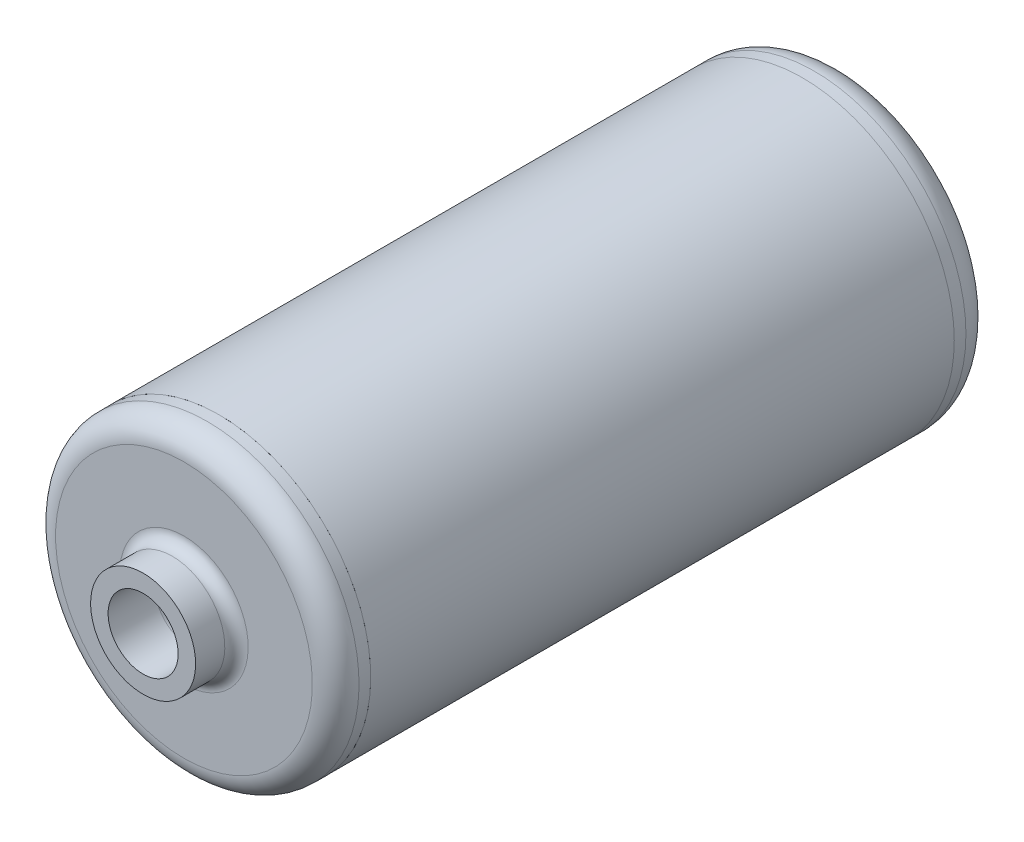
from build123d import *

# Parameters (mm, degrees)
SALIENTE_EXTRUIR1_DEPTH      = 50
SALIENTE_EXTRUIR1_DEPTH_BACK = 50
CROQUIS1_R                   = 26
CROQUIS1_R_2                 = 22


with BuildPart() as part:
    # Croquis1 → Saliente-Extruir1 (new, two sides: drawn at the far end of the back side and taken through both)
    with BuildSketch(Plane.XY.offset(-SALIENTE_EXTRUIR1_DEPTH_BACK)):
        Circle(CROQUIS1_R)
        Circle(CROQUIS1_R_2, mode=Mode.SUBTRACT)
    extrude(amount=SALIENTE_EXTRUIR1_DEPTH + SALIENTE_EXTRUIR1_DEPTH_BACK)


with BuildPart() as body_2:
    # Croquis2 → Revolución2 (revolve)
    with BuildSketch(Plane(origin=(0, 0, 0), x_dir=(0, 0, -1), z_dir=(1, 0, 0))):
        with BuildLine():
            Line((-50, 22), (-43, 22))
            Line((-43, 22), (-43, 21))
            ThreePointArc((-43, 21), (-43.585786438, 19.585786438), (-45, 19))
            Line((-45, 19), (-49, 19))
            ThreePointArc((-49, 19), (-51.828427125, 17.828427125), (-53, 15))
            Line((-53, 15), (-53, 8))
            ThreePointArc((-53, 8), (-53.585786438, 6.585786438), (-55, 6))
            Line((-55, 6), (-63, 6))
            Line((-63, 6), (-63, 9))
            Line((-63, 9), (-58, 9))
            ThreePointArc((-58, 9), (-56.585786438, 9.585786438), (-56, 11))
            Line((-56, 11), (-56, 22))
            ThreePointArc((-56, 22), (-54.828427125, 24.828427125), (-52, 26))
            Line((-52, 26), (-50, 26))
            Line((-50, 26), (-50, 22))
        make_face()
    revolve(axis=Axis((0, 0, -65.987324402), (0, 0, 1)))


with BuildPart() as body_3:
    # Croquis3 → Revolución3 (revolve)
    with BuildSketch(Plane(origin=(0, 0, 0), x_dir=(0, 0, -1), z_dir=(1, 0, 0))):
        with BuildLine():
            Line((45, 22), (50, 22))
            Line((50, 22), (50, 26))
            Line((50, 26), (52, 26))
            ThreePointArc((52, 26), (55.535533906, 24.535533906), (57, 21))
            Line((57, 21), (57, 8))
            ThreePointArc((57, 8), (56.414213562, 6.585786438), (55, 6))
            Line((55, 6), (45, 6))
            ThreePointArc((45, 6), (43.585786438, 6.585786438), (43, 8))
            Line((43, 8), (43, 20))
            ThreePointArc((43, 20), (43.585786438, 21.414213562), (45, 22))
        make_face()
    revolve(axis=Axis((0, 0, 0), (0, 0, -1)))


solid = Compound([part.part, body_2.part, body_3.part])
